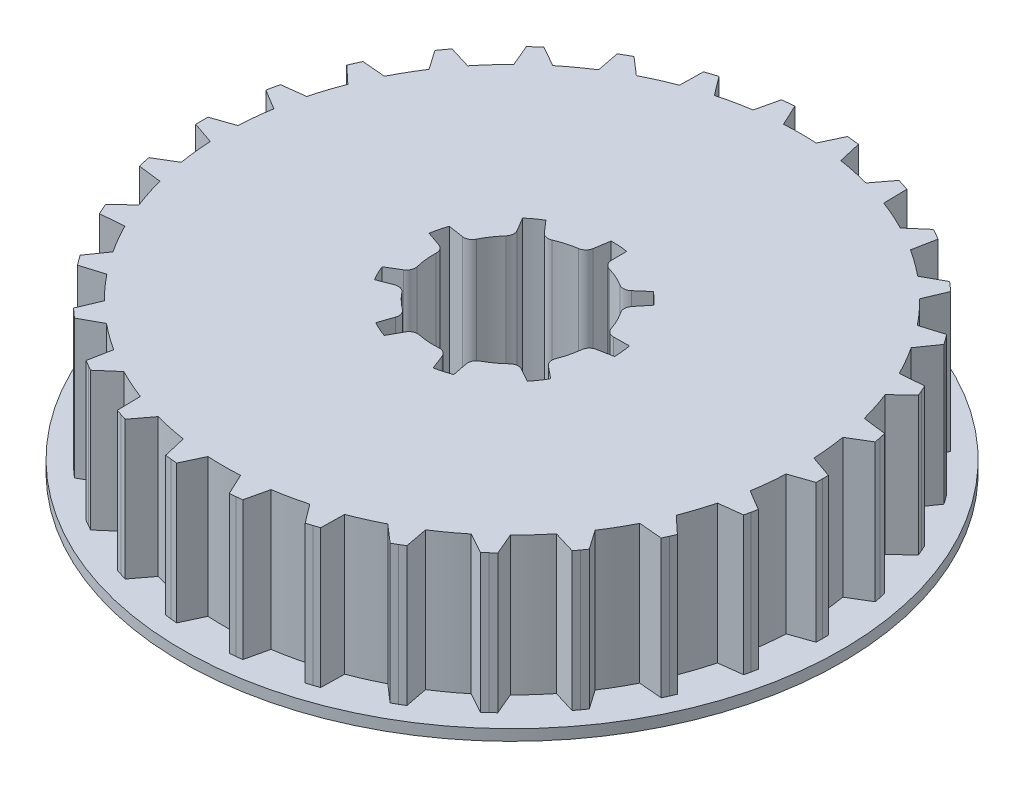
from build123d import *

# Parameters (mm, degrees)
SKETCH1_R           = 13.12
BOSS_EXTRUDE1_DEPTH = 6.3
BOSS_EXTRUDE2_DEPTH = 6.3
CUT_EXTRUDE1_DEPTH  = 10
SKETCH4_R           = 15
BOSS_EXTRUDE3_DEPTH = 0.5
CUT_EXTRUDE2_DEPTH  = 5.5


with BuildPart() as part:
    # Sketch1 → Boss-Extrude1 (new body)
    with BuildSketch(Plane(origin=(0, 0, 0), x_dir=(1, 0, 0), z_dir=(0, 1, 0))):
        Circle(SKETCH1_R)
    extrude(amount=BOSS_EXTRUDE1_DEPTH)

    # Sketch2 → Boss-Extrude2 (add)
    with BuildSketch(Plane.XZ):
        with BuildLine():
            Line((-14.12, 0), (-14.117223796, -0.279986237))
            Line((-14.117223796, -0.279986237), (-12.594228558, -0.806106083))
            ThreePointArc((-12.594228558, -0.806106083), (-12.62, -3.533e-06), (-12.59422901, 0.806099032))
            Line((-12.59422901, 0.806099032), (-14.117223523, 0.28))
            Line((-14.117223523, 0.28), (-14.12, 0))
        make_face()
        with BuildLine():
            Line((-13.866940997, 2.661268004), (-12.486613326, 1.829996623))
            ThreePointArc((-12.486613326, 1.829996623), (-12.344223456, 2.623842083), (-12.151417476, 3.406971282))
            Line((-12.151417476, 3.406971282), (-13.750513045, 3.209017141))
            Line((-13.750513045, 3.209017141), (-13.811444122, 2.935713074))
            Line((-13.811444122, 2.935713074), (-13.866940997, 2.661268004))
        make_face()
        with BuildLine():
            Line((-13.010606335, 5.486212062), (-11.833273174, 4.386119696))
            ThreePointArc((-11.833273174, 4.386119696), (-11.528945112, 5.133013208), (-11.17753069, 5.858942538))
            Line((-11.17753069, 5.858942538), (-12.782839164, 5.997784833))
            Line((-12.782839164, 5.997784833), (-12.899261862, 5.7431214))
            Line((-12.899261862, 5.7431214), (-13.010606335, 5.486212062))
        make_face()
        with BuildLine():
            Line((-11.585645745, 8.071382327), (-10.662762202, 6.750548291))
            ThreePointArc((-10.662762202, 6.750548291), (-10.209796545, 7.417847026), (-9.715132177, 8.054849892))
            Line((-9.715132177, 8.054849892), (-11.256493873, 8.524420549))
            Line((-11.256493873, 8.524420549), (-11.423319961, 8.299527762))
            Line((-11.423319961, 8.299527762), (-11.585645745, 8.071382327))
        make_face()
        with BuildLine():
            Line((-9.654336842, 10.303794454), (-9.026237356, 8.819945532))
            ThreePointArc((-9.026237356, 8.819945532), (-8.444430878, 9.378485334), (-7.82813577, 9.898721653))
            Line((-7.82813577, 9.898721653), (-9.238185785, 10.678498181))
            Line((-9.238185785, 10.678498181), (-9.448124162, 10.493204936))
            Line((-9.448124162, 10.493204936), (-9.654336842, 10.303794454))
        make_face()
        with BuildLine():
            Line((-7.301087092, 12.08588132), (-6.995222625, 10.503868831))
            ThreePointArc((-6.995222625, 10.503868831), (-6.310003059, 10.929238829), (-5.599012265, 11.309971779))
            Line((-5.599012265, 11.309971779), (-6.816124648, 12.365874202))
            Line((-6.816124648, 12.365874202), (-7.06, 12.228278701))
            Line((-7.06, 12.228278701), (-7.301087092, 12.08588132))
        make_face()
        with BuildLine():
            Line((-4.628744801, 13.339757178), (-4.658483098, 11.728722659))
            ThreePointArc((-4.658483098, 11.728722659), (-3.899797829, 12.002332144), (-3.125185058, 12.226921867))
            Line((-3.125185058, 12.226921867), (-4.096166157, 13.512802182))
            Line((-4.096166157, 13.512802182), (-4.363319961, 13.42891801))
            Line((-4.363319961, 13.42891801), (-4.628744801, 13.339757178))
        make_face()
        with BuildLine():
            Line((-1.754104152, 14.010621636), (-2.118145506, 12.440975027))
            ThreePointArc((-2.118145506, 12.440975027), (-1.31915272, 12.55086595), (-0.514772268, 12.609496799))
            Line((-0.514772268, 12.609496799), (-1.19718555, 14.069155865))
            Line((-1.19718555, 14.069155865), (-1.475941901, 14.042649163))
            Line((-1.475941901, 14.042649163), (-1.754104152, 14.010621636))
        make_face()
        with BuildLine():
            Line((1.197199266, 14.069154698), (0.514765208, 12.609497087))
            ThreePointArc((0.514765208, 12.609497087), (1.319145693, 12.550866689), (2.118138541, 12.440976212))
            Line((2.118138541, 12.440976212), (1.754117811, 14.010619926))
            Line((1.754117811, 14.010619926), (1.475941901, 14.042649163))
            Line((1.475941901, 14.042649163), (1.197199266, 14.069154698))
        make_face()
        with BuildLine():
            Line((4.096179332, 13.512798189), (3.125178213, 12.226923617))
            ThreePointArc((3.125178213, 12.226923617), (3.899791109, 12.002334327), (4.658476532, 11.728725268))
            Line((4.658476532, 11.728725268), (4.628757807, 13.339752665))
            Line((4.628757807, 13.339752665), (4.363319961, 13.42891801))
            Line((4.363319961, 13.42891801), (4.096179332, 13.512798189))
        make_face()
        with BuildLine():
            Line((6.816136704, 12.365867557), (5.599005934, 11.309974914))
            ThreePointArc((5.599005934, 11.309974914), (6.309996941, 10.929242362), (6.995216744, 10.503872748))
            Line((6.995216744, 10.503872748), (7.301098875, 12.085874202))
            Line((7.301098875, 12.085874202), (7.06, 12.228278701))
            Line((7.06, 12.228278701), (6.816136704, 12.365867557))
        make_face()
        with BuildLine():
            Line((9.238196196, 10.678489174), (7.828130228, 9.898726036))
            ThreePointArc((7.828130228, 9.898726036), (8.444425627, 9.378490061), (9.026232418, 8.819950586))
            Line((9.026232418, 8.819950586), (9.654346887, 10.303785041))
            Line((9.654346887, 10.303785041), (9.448124162, 10.493204936))
            Line((9.448124162, 10.493204936), (9.238196196, 10.678489174))
        make_face()
        with BuildLine():
            Line((11.256502184, 8.524409574), (9.715127668, 8.054855331))
            ThreePointArc((9.715127668, 8.054855331), (10.209792393, 7.417852742), (10.662758423, 6.75055426))
            Line((10.662758423, 6.75055426), (11.585653614, 8.071371032))
            Line((11.585653614, 8.071371032), (11.423319961, 8.299527762))
            Line((11.423319961, 8.299527762), (11.256502184, 8.524409574))
        make_face()
        with BuildLine():
            Line((12.782845011, 5.997772371), (11.17752741, 5.858948796))
            ThreePointArc((11.17752741, 5.858948796), (11.528942239, 5.133019663), (11.833270719, 4.386126321))
            Line((11.833270719, 4.386126321), (13.010611684, 5.486199377))
            Line((13.010611684, 5.486199377), (12.899261862, 5.7431214))
            Line((12.899261862, 5.7431214), (12.782845011, 5.997772371))
        make_face()
        with BuildLine():
            Line((13.750516173, 3.209003735), (12.151415569, 3.406978085))
            ThreePointArc((12.151415569, 3.406978085), (12.344221987, 2.623848994), (12.486612302, 1.830003614))
            Line((12.486612302, 1.830003614), (13.866943592, 2.661254484))
            Line((13.866943592, 2.661254484), (13.811444122, 2.935713074))
            Line((13.811444122, 2.935713074), (13.750516173, 3.209003735))
        make_face()
        with BuildLine():
            Line((14.117223796, 0.279986237), (12.594228558, 0.806106083))
            ThreePointArc((12.594228558, 0.806106083), (12.62, 3.533e-06), (12.59422901, -0.806099032))
            Line((12.59422901, -0.806099032), (14.117223523, -0.28))
            Line((14.117223523, -0.28), (14.12, 0))
            Line((14.12, 0), (14.117223796, 0.279986237))
        make_face()
        with BuildLine():
            Line((13.866940997, -2.661268004), (12.486613326, -1.829996623))
            ThreePointArc((12.486613326, -1.829996623), (12.344223456, -2.623842083), (12.151417476, -3.406971282))
            Line((12.151417476, -3.406971282), (13.750513045, -3.209017141))
            Line((13.750513045, -3.209017141), (13.811444122, -2.935713074))
            Line((13.811444122, -2.935713074), (13.866940997, -2.661268004))
        make_face()
        with BuildLine():
            Line((13.010606335, -5.486212062), (11.833273174, -4.386119696))
            ThreePointArc((11.833273174, -4.386119696), (11.528945112, -5.133013208), (11.17753069, -5.858942538))
            Line((11.17753069, -5.858942538), (12.782839164, -5.997784833))
            Line((12.782839164, -5.997784833), (12.899261862, -5.7431214))
            Line((12.899261862, -5.7431214), (13.010606335, -5.486212062))
        make_face()
        with BuildLine():
            Line((11.585645745, -8.071382327), (10.662762202, -6.750548291))
            ThreePointArc((10.662762202, -6.750548291), (10.209796545, -7.417847026), (9.715132177, -8.054849892))
            Line((9.715132177, -8.054849892), (11.256493873, -8.524420549))
            Line((11.256493873, -8.524420549), (11.423319961, -8.299527762))
            Line((11.423319961, -8.299527762), (11.585645745, -8.071382327))
        make_face()
        with BuildLine():
            Line((9.654336842, -10.303794454), (9.026237356, -8.819945532))
            ThreePointArc((9.026237356, -8.819945532), (8.444430878, -9.378485334), (7.82813577, -9.898721653))
            Line((7.82813577, -9.898721653), (9.238185785, -10.678498181))
            Line((9.238185785, -10.678498181), (9.448124162, -10.493204936))
            Line((9.448124162, -10.493204936), (9.654336842, -10.303794454))
        make_face()
        with BuildLine():
            Line((7.301087092, -12.08588132), (6.995222625, -10.503868831))
            ThreePointArc((6.995222625, -10.503868831), (6.310003059, -10.929238829), (5.599012265, -11.309971779))
            Line((5.599012265, -11.309971779), (6.816124648, -12.365874202))
            Line((6.816124648, -12.365874202), (7.06, -12.228278701))
            Line((7.06, -12.228278701), (7.301087092, -12.08588132))
        make_face()
        with BuildLine():
            Line((4.628744801, -13.339757178), (4.658483098, -11.728722659))
            ThreePointArc((4.658483098, -11.728722659), (3.899797829, -12.002332144), (3.125185058, -12.226921867))
            Line((3.125185058, -12.226921867), (4.096166157, -13.512802182))
            Line((4.096166157, -13.512802182), (4.363319961, -13.42891801))
            Line((4.363319961, -13.42891801), (4.628744801, -13.339757178))
        make_face()
        with BuildLine():
            Line((1.754104152, -14.010621636), (2.118145506, -12.440975027))
            ThreePointArc((2.118145506, -12.440975027), (1.31915272, -12.55086595), (0.514772268, -12.609496799))
            Line((0.514772268, -12.609496799), (1.19718555, -14.069155865))
            Line((1.19718555, -14.069155865), (1.475941901, -14.042649163))
            Line((1.475941901, -14.042649163), (1.754104152, -14.010621636))
        make_face()
        with BuildLine():
            Line((-1.197199266, -14.069154698), (-0.514765208, -12.609497087))
            ThreePointArc((-0.514765208, -12.609497087), (-1.319145693, -12.550866689), (-2.118138541, -12.440976212))
            Line((-2.118138541, -12.440976212), (-1.754117811, -14.010619926))
            Line((-1.754117811, -14.010619926), (-1.475941901, -14.042649163))
            Line((-1.475941901, -14.042649163), (-1.197199266, -14.069154698))
        make_face()
        with BuildLine():
            Line((-4.096179332, -13.512798189), (-3.125178213, -12.226923617))
            ThreePointArc((-3.125178213, -12.226923617), (-3.899791109, -12.002334327), (-4.658476532, -11.728725268))
            Line((-4.658476532, -11.728725268), (-4.628757807, -13.339752665))
            Line((-4.628757807, -13.339752665), (-4.363319961, -13.42891801))
            Line((-4.363319961, -13.42891801), (-4.096179332, -13.512798189))
        make_face()
        with BuildLine():
            Line((-6.816136704, -12.365867557), (-5.599005934, -11.309974914))
            ThreePointArc((-5.599005934, -11.309974914), (-6.309996941, -10.929242362), (-6.995216744, -10.503872748))
            Line((-6.995216744, -10.503872748), (-7.301098875, -12.085874202))
            Line((-7.301098875, -12.085874202), (-7.06, -12.228278701))
            Line((-7.06, -12.228278701), (-6.816136704, -12.365867557))
        make_face()
        with BuildLine():
            Line((-9.238196196, -10.678489174), (-7.828130228, -9.898726036))
            ThreePointArc((-7.828130228, -9.898726036), (-8.444425627, -9.378490061), (-9.026232418, -8.819950586))
            Line((-9.026232418, -8.819950586), (-9.654346887, -10.303785041))
            Line((-9.654346887, -10.303785041), (-9.448124162, -10.493204936))
            Line((-9.448124162, -10.493204936), (-9.238196196, -10.678489174))
        make_face()
        with BuildLine():
            Line((-11.256502184, -8.524409574), (-9.715127668, -8.054855331))
            ThreePointArc((-9.715127668, -8.054855331), (-10.209792393, -7.417852742), (-10.662758423, -6.75055426))
            Line((-10.662758423, -6.75055426), (-11.585653614, -8.071371032))
            Line((-11.585653614, -8.071371032), (-11.423319961, -8.299527762))
            Line((-11.423319961, -8.299527762), (-11.256502184, -8.524409574))
        make_face()
        with BuildLine():
            Line((-12.782845011, -5.997772371), (-11.17752741, -5.858948796))
            ThreePointArc((-11.17752741, -5.858948796), (-11.528942239, -5.133019663), (-11.833270719, -4.386126321))
            Line((-11.833270719, -4.386126321), (-13.010611684, -5.486199377))
            Line((-13.010611684, -5.486199377), (-12.899261862, -5.7431214))
            Line((-12.899261862, -5.7431214), (-12.782845011, -5.997772371))
        make_face()
        with BuildLine():
            Line((-13.750516173, -3.209003735), (-12.151415569, -3.406978085))
            ThreePointArc((-12.151415569, -3.406978085), (-12.344221987, -2.623848994), (-12.486612302, -1.830003614))
            Line((-12.486612302, -1.830003614), (-13.866943592, -2.661254484))
            Line((-13.866943592, -2.661254484), (-13.811444122, -2.935713074))
            Line((-13.811444122, -2.935713074), (-13.750516173, -3.209003735))
        make_face()
    extrude(amount=-BOSS_EXTRUDE2_DEPTH)

    # Sketch3 → Cut-Extrude1 (cut)
    with BuildSketch(Plane(origin=(0, 6.3, 0), x_dir=(1, 0, 0), z_dir=(0, 1, 0))):
        with BuildLine():
            Line((-3.926399134, -2.338437479), (-3.261863038, -2.083345972))
            ThreePointArc((-3.261863038, -2.083345972), (-3.012398307, -2.071111103), (-2.804307711, -2.209243821))
            ThreePointArc((-2.804307711, -2.209243821), (-2.479930383, -2.568043087), (-2.110029082, -2.8797009))
            ThreePointArc((-2.110029082, -2.8797009), (-1.964718254, -3.082843971), (-1.968239476, -3.332583725))
            Line((-1.968239476, -3.332583725), (-2.199983613, -4.005617568))
            ThreePointArc((-2.199983613, -4.005617568), (-1.858786459, -4.174902741), (-1.5046776, -4.31518775))
            Line((-1.5046776, -4.31518775), (-1.159583077, -3.69262075))
            ThreePointArc((-1.159583077, -3.69262075), (-0.976346428, -3.522895459), (-0.728149784, -3.494953203))
            ThreePointArc((-0.728149784, -3.494953203), (-0.249030611, -3.561303659), (0.234660005, -3.562279422))
            ThreePointArc((0.234660005, -3.562279422), (0.476552407, -3.624492043), (0.634384614, -3.818067192))
            Line((0.634384614, -3.818067192), (0.889476121, -4.482603287))
            ThreePointArc((0.889476121, -4.482603287), (1.259662716, -4.39296595), (1.621099305, -4.272813715))
            Line((1.621099305, -4.272813715), (1.485278693, -3.574077241))
            ThreePointArc((1.485278693, -3.574077241), (1.516548795, -3.326277877), (1.68871752, -3.145335139))
            ThreePointArc((1.68871752, -3.145335139), (2.098393351, -2.88819067), (2.469549068, -2.578027812))
            ThreePointArc((2.469549068, -2.578027812), (2.694838899, -2.470200006), (2.940173092, -2.517034586))
            Line((2.940173092, -2.517034586), (3.562740092, -2.862129109))
            ThreePointArc((3.562740092, -2.862129109), (3.788701707, -2.555511569), (3.988345829, -2.231142655))
            Line((3.988345829, -2.231142655), (3.435162056, -1.783183268))
            ThreePointArc((3.435162056, -1.783183268), (3.299833983, -1.573257909), (3.315415128, -1.323979807))
            ThreePointArc((3.315415128, -1.323979807), (3.463955743, -0.863661167), (3.548908676, -0.387488337))
            ThreePointArc((3.548908676, -0.387488337), (3.652180321, -0.160073933), (3.870221904, -0.038253524))
            Line((3.870221904, -0.038253524), (4.568958378, 0.097567088))
            ThreePointArc((4.568958378, 0.097567088), (4.544965062, 0.477695077), (4.489401014, 0.854504849))
            Line((4.489401014, 0.854504849), (3.777694915, 0.842081973))
            ThreePointArc((3.777694915, 0.842081973), (3.539090177, 0.91590692), (3.390793151, 1.116880391))
            ThreePointArc((3.390793151, 1.116880391), (3.208694745, 1.564984994), (2.967694472, 1.984361237))
            ThreePointArc((2.967694472, 1.984361237), (2.900625981, 2.224952512), (2.989350875, 2.458426787))
            Line((2.989350875, 2.458426787), (3.437310262, 3.01161056))
            ThreePointArc((3.437310262, 3.01161056), (3.174588753, 3.287382888), (2.88981557, 3.540320038))
            Line((2.88981557, 3.540320038), (2.352602339, 3.0733277))
            ThreePointArc((2.352602339, 3.0733277), (2.122366744, 2.976508721), (1.879581374, 3.035139841))
            ThreePointArc((1.879581374, 3.035139841), (1.452049816, 3.261357284), (0.997863043, 3.427706135))
            ThreePointArc((0.997863043, 3.427706135), (0.791836508, 3.568898949), (0.709729348, 3.804781882))
            Line((0.709729348, 3.804781882), (0.697306472, 4.516487981))
            ThreePointArc((0.697306472, 4.516487981), (0.318787085, 4.55886771), (-0.061946695, 4.569580135))
            Line((-0.061946695, 4.569580135), (-0.173299018, 3.866529241))
            ThreePointArc((-0.173299018, 3.866529241), (-0.287435676, 3.644369012), (-0.511107417, 3.533223628))
            ThreePointArc((-0.511107417, 3.533223628), (-0.98402536, 3.431704254), (-1.438879594, 3.267189238))
            ThreePointArc((-1.438879594, 3.267189238), (-1.687462068, 3.242917904), (-1.901982428, 3.370837249))
            Line((-1.901982428, 3.370837249), (-2.368974766, 3.908050481))
            ThreePointArc((-2.368974766, 3.908050481), (-2.686178603, 3.697207664), (-2.984723414, 3.460682901))
            Line((-2.984723414, 3.460682901), (-2.618111838, 2.850538777))
            ThreePointArc((-2.618111838, 2.850538777), (-2.562743748, 2.606988539), (-2.662643367, 2.378072812))
            ThreePointArc((-2.662643367, 2.378072812), (-2.959664134, 1.996318665), (-3.202354478, 1.577918185))
            ThreePointArc((-3.202354478, 1.577918185), (-3.377178388, 1.399539531), (-3.623735488, 1.359640405))
            Line((-3.623735488, 1.359640405), (-4.326786382, 1.470992727))
            ThreePointArc((-4.326786382, 1.470992727), (-4.434251469, 1.105583063), (-4.510914875, 0.732493677))
            Line((-4.510914875, 0.732493677), (-3.837881032, 0.50074954))
            ThreePointArc((-3.837881032, 0.50074954), (-3.638915539, 0.349769156), (-3.568298894, 0.110195298))
            ThreePointArc((-3.568298894, 0.110195298), (-3.550443166, -0.373166614), (-3.467412111, -0.849678323))
            ThreePointArc((-3.467412111, -0.849678323), (-3.486675407, -1.098698943), (-3.64990244, -1.287747296))
            Line((-3.64990244, -1.287747296), (-4.260046564, -1.654358872))
            ThreePointArc((-4.260046564, -1.654358872), (-4.107488792, -2.003356141), (-3.926399134, -2.338437479))
        make_face()
    extrude(amount=-CUT_EXTRUDE1_DEPTH, mode=Mode.SUBTRACT)

    # Sketch4 → Boss-Extrude3 (add)
    with BuildSketch(Plane.XZ):
        Circle(SKETCH4_R)
    extrude(amount=BOSS_EXTRUDE3_DEPTH)

    # Sketch5 → Cut-Extrude2 (cut)
    with BuildSketch(Plane(origin=(0, 0, 0), x_dir=(1, 0, 0), z_dir=(0, 1, 0))):
        with BuildLine():
            Line((-3.64990244, -1.287747296), (-4.260046564, -1.654358872))
            ThreePointArc((-4.260046564, -1.654358872), (-4.107488792, -2.003356141), (-3.926399134, -2.338437479))
            Line((-3.926399134, -2.338437479), (-3.261863038, -2.083345972))
            ThreePointArc((-3.261863038, -2.083345972), (-3.012398307, -2.071111103), (-2.804307711, -2.209243821))
            ThreePointArc((-2.804307711, -2.209243821), (-2.479930383, -2.568043087), (-2.110029082, -2.8797009))
            ThreePointArc((-2.110029082, -2.8797009), (-1.964718254, -3.082843971), (-1.968239476, -3.332583725))
            Line((-1.968239476, -3.332583725), (-2.199983613, -4.005617568))
            ThreePointArc((-2.199983613, -4.005617568), (-1.858786459, -4.174902741), (-1.5046776, -4.31518775))
            Line((-1.5046776, -4.31518775), (-1.159583077, -3.69262075))
            ThreePointArc((-1.159583077, -3.69262075), (-0.976346428, -3.522895459), (-0.728149784, -3.494953203))
            ThreePointArc((-0.728149784, -3.494953203), (-0.249030611, -3.561303659), (0.234660005, -3.562279422))
            ThreePointArc((0.234660005, -3.562279422), (0.476552407, -3.624492043), (0.634384614, -3.818067192))
            Line((0.634384614, -3.818067192), (0.889476121, -4.482603287))
            ThreePointArc((0.889476121, -4.482603287), (1.259662716, -4.39296595), (1.621099305, -4.272813715))
            Line((1.621099305, -4.272813715), (1.485278693, -3.574077241))
            ThreePointArc((1.485278693, -3.574077241), (1.516548795, -3.326277877), (1.68871752, -3.145335139))
            ThreePointArc((1.68871752, -3.145335139), (2.098393351, -2.88819067), (2.469549068, -2.578027812))
            ThreePointArc((2.469549068, -2.578027812), (2.694838899, -2.470200006), (2.940173092, -2.517034586))
            Line((2.940173092, -2.517034586), (3.562740092, -2.862129109))
            ThreePointArc((3.562740092, -2.862129109), (3.788701707, -2.555511569), (3.988345829, -2.231142655))
            Line((3.988345829, -2.231142655), (3.435162056, -1.783183268))
            ThreePointArc((3.435162056, -1.783183268), (3.299833983, -1.573257909), (3.315415128, -1.323979807))
            ThreePointArc((3.315415128, -1.323979807), (3.463955743, -0.863661167), (3.548908676, -0.387488337))
            ThreePointArc((3.548908676, -0.387488337), (3.652180321, -0.160073933), (3.870221904, -0.038253524))
            Line((3.870221904, -0.038253524), (4.568958378, 0.097567088))
            ThreePointArc((4.568958378, 0.097567088), (4.544965062, 0.477695077), (4.489401014, 0.854504849))
            Line((4.489401014, 0.854504849), (3.777694915, 0.842081973))
            ThreePointArc((3.777694915, 0.842081973), (3.539090177, 0.91590692), (3.390793151, 1.116880391))
            ThreePointArc((3.390793151, 1.116880391), (3.208694745, 1.564984994), (2.967694472, 1.984361237))
            ThreePointArc((2.967694472, 1.984361237), (2.900625981, 2.224952512), (2.989350875, 2.458426787))
            Line((2.989350875, 2.458426787), (3.437310262, 3.01161056))
            ThreePointArc((3.437310262, 3.01161056), (3.174588753, 3.287382888), (2.88981557, 3.540320038))
            Line((2.88981557, 3.540320038), (2.352602339, 3.0733277))
            ThreePointArc((2.352602339, 3.0733277), (2.122366744, 2.976508721), (1.879581374, 3.035139841))
            ThreePointArc((1.879581374, 3.035139841), (1.452049816, 3.261357284), (0.997863043, 3.427706135))
            ThreePointArc((0.997863043, 3.427706135), (0.791836508, 3.568898949), (0.709729348, 3.804781882))
            Line((0.709729348, 3.804781882), (0.697306472, 4.516487981))
            ThreePointArc((0.697306472, 4.516487981), (0.318787085, 4.55886771), (-0.061946695, 4.569580135))
            Line((-0.061946695, 4.569580135), (-0.173299018, 3.866529241))
            ThreePointArc((-0.173299018, 3.866529241), (-0.287435676, 3.644369012), (-0.511107417, 3.533223628))
            ThreePointArc((-0.511107417, 3.533223628), (-0.98402536, 3.431704254), (-1.438879594, 3.267189238))
            ThreePointArc((-1.438879594, 3.267189238), (-1.687462068, 3.242917904), (-1.901982428, 3.370837249))
            Line((-1.901982428, 3.370837249), (-2.368974766, 3.908050481))
            ThreePointArc((-2.368974766, 3.908050481), (-2.686178603, 3.697207664), (-2.984723414, 3.460682901))
            Line((-2.984723414, 3.460682901), (-2.618111838, 2.850538777))
            ThreePointArc((-2.618111838, 2.850538777), (-2.562743748, 2.606988539), (-2.662643367, 2.378072812))
            ThreePointArc((-2.662643367, 2.378072812), (-2.959664134, 1.996318665), (-3.202354478, 1.577918185))
            ThreePointArc((-3.202354478, 1.577918185), (-3.377178388, 1.399539531), (-3.623735488, 1.359640405))
            Line((-3.623735488, 1.359640405), (-4.326786382, 1.470992727))
            ThreePointArc((-4.326786382, 1.470992727), (-4.434251469, 1.105583063), (-4.510914875, 0.732493677))
            Line((-4.510914875, 0.732493677), (-3.837881032, 0.50074954))
            ThreePointArc((-3.837881032, 0.50074954), (-3.638915539, 0.349769156), (-3.568298894, 0.110195298))
            ThreePointArc((-3.568298894, 0.110195298), (-3.550443166, -0.373166614), (-3.467412111, -0.849678323))
            ThreePointArc((-3.467412111, -0.849678323), (-3.486675407, -1.098698943), (-3.64990244, -1.287747296))
        make_face()
    extrude(amount=-CUT_EXTRUDE2_DEPTH, mode=Mode.SUBTRACT)


solid = part.part
